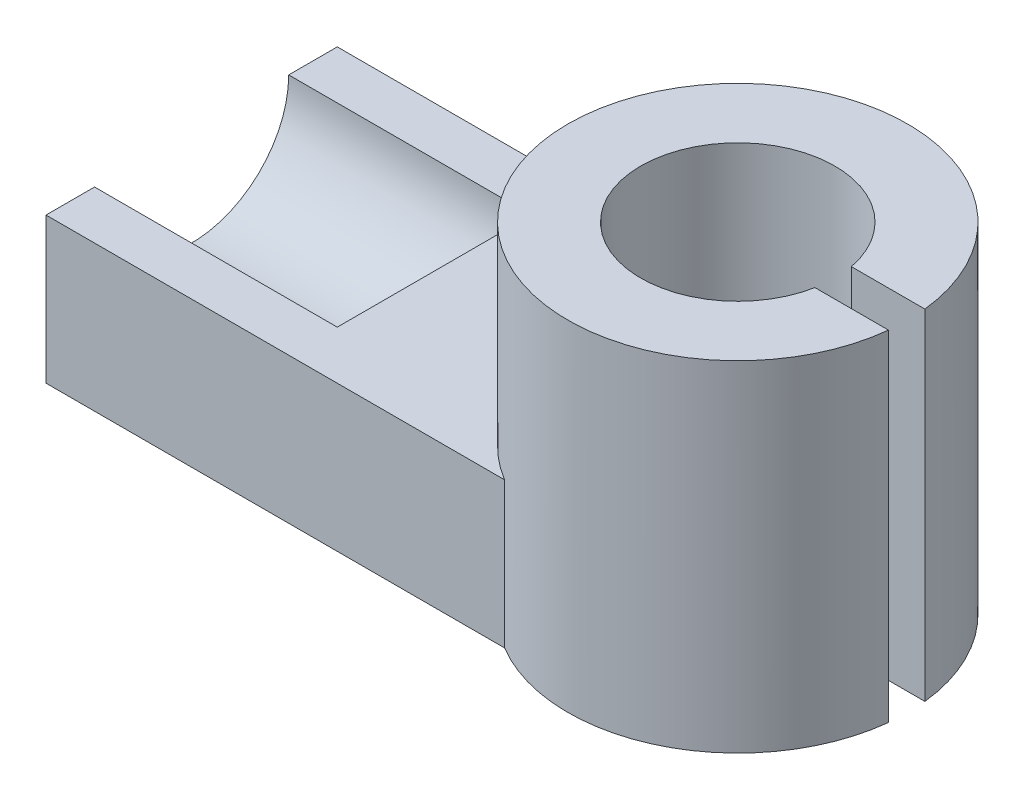
from build123d import *

# Parameters (mm, degrees)
BOSS_EXTRUDE4_DEPTH = 56
BOSS_EXTRUDE5_DEPTH = 24
SKETCH7_R           = 16
CUT_EXTRUDE1_DEPTH  = 40


with BuildPart() as part:
    # Sketch5 → Boss-Extrude4 (new body)
    with BuildSketch(Plane(origin=(0, 0, 0), x_dir=(1, 0, 0), z_dir=(0, 1, 0))):
        with BuildLine():
            Line((27.838821814, -3), (15.716233646, -3))
            ThreePointArc((15.716233646, -3), (-16, 0), (15.716233646, 3))
            Line((15.716233646, 3), (27.838821814, 3))
            ThreePointArc((27.838821814, 3), (-28, 0), (27.838821814, -3))
        make_face()
    extrude(amount=BOSS_EXTRUDE4_DEPTH)

    # Sketch6 → Boss-Extrude5 (add)
    with BuildSketch(Plane(origin=(0, 0, 0), x_dir=(1, 0, 0), z_dir=(0, 1, 0))):
        with BuildLine():
            Line((-90, 24), (-90, -24))
            Line((-90, -24), (-14.422205102, -24))
            ThreePointArc((-14.422205102, -24), (-28, 0), (-14.422205102, 24))
            Line((-14.422205102, 24), (-90, 24))
        make_face()
    extrude(amount=BOSS_EXTRUDE5_DEPTH)

    # Sketch7 → Cut-Extrude1 (cut)
    with BuildSketch(Plane.ZY.offset(90)):
        with Locations((0, 24)):
            Circle(SKETCH7_R)
    extrude(amount=-CUT_EXTRUDE1_DEPTH, mode=Mode.SUBTRACT)


solid = part.part
